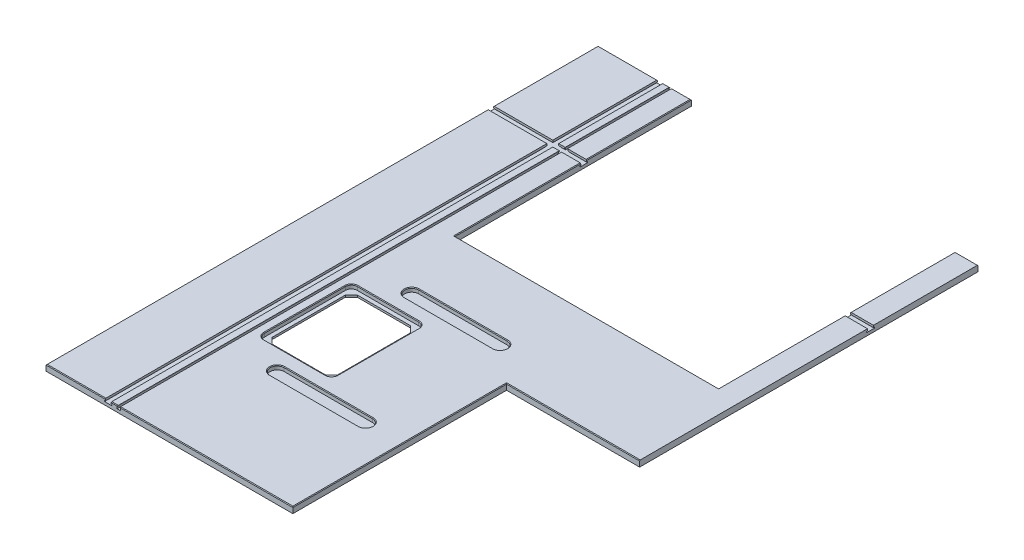
from build123d import *

# Parameters (mm, degrees)
SKETCH1_W           = 1219.2
SKETCH1_H           = 1771.65
BOSS_EXTRUDE1_DEPTH = 19.05
SKETCH3_W           = 508
SKETCH3_H           = 685.8
CUT_EXTRUDE2_DEPTH  = 20.05
SKETCH5_W           = 846.4296
SKETCH5_H           = 758.825
CUT_EXTRUDE4_DEPTH  = 20.05
CUT_EXTRUDE12_DEPTH = 846.4296
CUT_EXTRUDE5_DEPTH  = 12.7
CUT_EXTRUDE6_DEPTH  = 7.35
CUT_EXTRUDE11_DEPTH = 12.7
CUT_EXTRUDE8_DEPTH  = 1772.65
CUT_EXTRUDE10_DEPTH = 1220.2
CHAMFER2_SIZE       = 2.032


with BuildPart() as part:
    # Sketch1 → Boss-Extrude1 (new body)
    with BuildSketch(Plane(origin=(0, 0, 0), x_dir=(1, 0, 0), z_dir=(0, 1, 0))):
        with Locations((609.6, 885.825)):
            Rectangle(SKETCH1_W, SKETCH1_H)
    extrude(amount=-BOSS_EXTRUDE1_DEPTH)

    # Sketch3 → Cut-Extrude2 (cut, through all)
    with BuildSketch(Plane(origin=(0, 0, 0), x_dir=(1, 0, 0), z_dir=(0, 1, 0))):
        with Locations((1046.1625, 342.9)):
            Rectangle(SKETCH3_W, SKETCH3_H)
    extrude(amount=-CUT_EXTRUDE2_DEPTH, mode=Mode.SUBTRACT)

    # Sketch5 → Cut-Extrude4 (cut, through all)
    with BuildSketch(Plane(origin=(0, 0, 0), x_dir=(1, 0, 0), z_dir=(0, 1, 0))):
        with Locations((722.3252, 1392.2375)):
            Rectangle(SKETCH5_W, SKETCH5_H)
    extrude(amount=-CUT_EXTRUDE4_DEPTH, mode=Mode.SUBTRACT)

    # Sketch18 → Cut-Extrude12 (cut)
    with BuildSketch(Plane(origin=(299.1104, 0, 0), x_dir=(0, 0, -1), z_dir=(1, 0, 0))):
        with BuildLine():
            Line((1009.601754844, -19.05), (1771.65, -19.05))
            Line((1771.65, -19.05), (1771.65, 0))
            Line((1771.65, 0), (1014.82750315, 0))
            ThreePointArc((1014.82750315, 0), (1012.106135013, -9.495238202), (1009.601754844, -19.05))
        make_face()
    extrude(amount=CUT_EXTRUDE12_DEPTH, mode=Mode.SUBTRACT)

    # Sketch7 → Cut-Extrude5 (cut)
    with BuildSketch(Plane(origin=(0, 0, 0), x_dir=(1, 0, 0), z_dir=(0, 1, 0))):
        with BuildLine():
            Line((281.3685, 717.55), (478.2185, 717.55))
            ThreePointArc((478.2185, 717.55), (491.688884182, 711.970384182), (497.2685, 698.5))
            Line((497.2685, 698.5), (497.2685, 438.15))
            ThreePointArc((497.2685, 438.15), (491.688884182, 424.679615818), (478.2185, 419.1))
            Line((478.2185, 419.1), (281.3685, 419.1))
            ThreePointArc((281.3685, 419.1), (267.898115818, 424.679615818), (262.3185, 438.15))
            Line((262.3185, 438.15), (262.3185, 698.5))
            ThreePointArc((262.3185, 698.5), (267.898115818, 711.970384182), (281.3685, 717.55))
        make_face()
    extrude(amount=-CUT_EXTRUDE5_DEPTH, mode=Mode.SUBTRACT)

    # Sketch8 → Cut-Extrude6 (cut, through all)
    with BuildSketch(Plane(origin=(0, -12.7, 0), x_dir=(1, 0, 0), z_dir=(0, 1, 0))):
        Polygon((294.0685, 704.85), (275.0185, 685.8), (275.0185, 450.85), (294.0685, 431.8), (465.5185, 431.8), (484.5685, 450.85), (484.5685, 685.8), (465.5185, 704.85), align=None)
    extrude(amount=-CUT_EXTRUDE6_DEPTH, mode=Mode.SUBTRACT)

    # Sketch17 → Cut-Extrude11 (cut)
    with BuildSketch(Plane(origin=(0, 0, 0), x_dir=(1, 0, 0), z_dir=(0, 1, 0))):
        with BuildLine():
            Line((389.412860427, 806.45), (673.130860427, 806.45))
            ThreePointArc((673.130860427, 806.45), (695.355860427, 784.225), (673.130860427, 762))
            Line((673.130860427, 762), (389.412860427, 762))
            ThreePointArc((389.412860427, 762), (367.187860427, 784.225), (389.412860427, 806.45))
        make_face()
        with BuildLine():
            Line((389.412860427, 330.2), (673.130860427, 330.2))
            ThreePointArc((673.130860427, 330.2), (695.355860427, 352.425), (673.130860427, 374.65))
            Line((673.130860427, 374.65), (389.412860427, 374.65))
            ThreePointArc((389.412860427, 374.65), (367.187860427, 352.425), (389.412860427, 330.2))
        make_face()
    extrude(amount=-CUT_EXTRUDE11_DEPTH, mode=Mode.SUBTRACT)

    # Sketch12 → Cut-Extrude8 (cut, through all)
    with BuildSketch(Plane.XY):
        Polygon((209.2579, 0), (190.2079, 0), (190.2079, -6.096), (187.7949, -6.096), (187.7949, -9.525), (211.6709, -9.525), (211.6709, -6.096), (209.2579, -6.096), align=None)
        Polygon((237.4519, 0), (230.0859, 0), (230.0859, -2.54), (228.0539, -2.54), (228.0539, -9.525), (239.4839, -9.525), (239.4839, -2.54), (237.4519, -2.54), align=None)
    extrude(amount=-CUT_EXTRUDE8_DEPTH, mode=Mode.SUBTRACT)

    # Sketch16 → Cut-Extrude10 (cut, through all)
    with BuildSketch(Plane.ZY):
        Polygon((-1438.8084, -9.525), (-1414.4244, -9.525), (-1414.4244, -5.969), (-1417.0914, -5.969), (-1417.0914, 0), (-1436.1414, 0), (-1436.1414, -5.969), (-1438.8084, -5.969), align=None)
    extrude(amount=-CUT_EXTRUDE10_DEPTH, mode=Mode.SUBTRACT)

    # Chamfer2
    chamfer2_edges = [part.edges().sort_by_distance(p)[0] for p in [
        (367.187860427, 0, -784.225),
        (531.271860427, 0, -762),
        (695.355860427, 0, -784.225),
        (531.271860427, 0, -806.45),
        (367.187860427, 0, -352.425),
        (531.271860427, 0, -330.2),
        (695.355860427, 0, -352.425),
        (531.271860427, 0, -374.65),
        (1005.68125, 0, -685.8),
        (219.6719, 0, -1771.65),
        (95.10395, 0, -1771.65),
        (219.6719, 0, 0),
        (514.8072, 0, 0),
        (792.1625, 0, -342.9),
        (1145.54, 0, -1603.8957),
        (299.1104, 0, -1214.9582),
        (0, 0, -708.5457),
        (268.28115, 0, -1771.65),
        (299.1104, 0, -1603.8957),
        (722.3252, 0, -1012.825),
        (1145.54, 0, -1214.9582),
        (0, 0, -1603.8957),
        (1182.37, 0, -1771.65),
        (95.10395, 0, 0),
        (491.688884182, 0, -424.679615818),
        (497.2685, 0, -568.325),
        (491.688884182, 0, -711.970384182),
        (379.7935, 0, -717.55),
        (267.898115818, 0, -711.970384182),
        (262.3185, 0, -568.325),
        (267.898115818, 0, -424.679615818),
        (379.7935, 0, -419.1),
    ]]
    chamfer(chamfer2_edges, length=CHAMFER2_SIZE)


solid = part.part
